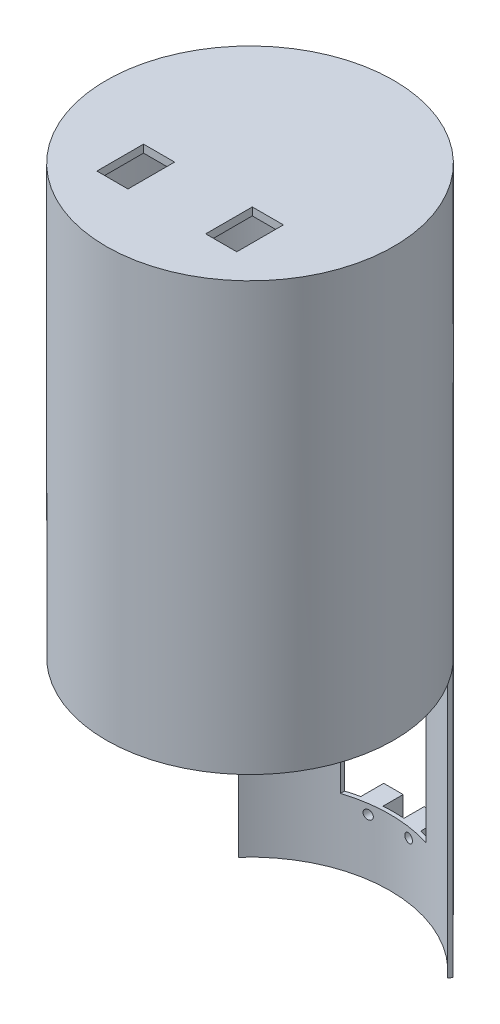
from build123d import *

# Parameters (mm, degrees)
SKETCH_1_R               = 37
EXTRUDE_1_DEPTH          = 110
EXTRUDE_1_DEPTH_BACK     = 70
SKETCH_2_R               = 36
CUT_EXTRUDE_1_DEPTH      = 108
CUT_EXTRUDE_1_DEPTH_BACK = 70
CUT_EXTRUDE_6_DEPTH      = 70
SKETCH_7_W               = 22
SKETCH_7_H               = 20
CUT_EXTRUDE_7_DEPTH      = 43
SKETCH_10_W              = 8
SKETCH_10_H              = 12
CUT_EXTRUDE_8_DEPTH      = 8.1
SKETCH_12_W              = 5
SKETCH_12_H              = 5
SKETCH_12_R              = 1.15
EXTRUDE_3_DEPTH          = 1
EXTRUDE_3_DEPTH_BACK     = 5.1
SKETCH_13_R              = 1.15
CUT_EXTRUDE_9_DEPTH      = 18.4


with BuildPart() as part:
    # 草圖1 → 填料-伸長1 (new body, two sides)
    with BuildSketch(Plane(origin=(0, 0, 0), x_dir=(1, 0, 0), z_dir=(0, 1, 0))) as extrude_1_sk:
        Circle(SKETCH_1_R)
    extrude(amount=EXTRUDE_1_DEPTH)
    extrude(extrude_1_sk.sketch, amount=-EXTRUDE_1_DEPTH_BACK)

    # 草圖2 → 除料-伸長1 (cut, two sides)
    with BuildSketch(Plane(origin=(0, 0, 0), x_dir=(1, 0, 0), z_dir=(0, 1, 0))) as cut_extrude_1_sk:
        Circle(SKETCH_2_R)
    extrude(amount=CUT_EXTRUDE_1_DEPTH, mode=Mode.SUBTRACT)
    extrude(cut_extrude_1_sk.sketch, amount=-CUT_EXTRUDE_1_DEPTH_BACK, mode=Mode.SUBTRACT)

    # 草圖6 → 除料-伸長6 (cut)
    with BuildSketch(Plane(origin=(0, 0, 0), x_dir=(1, 0, 0), z_dir=(0, 1, 0))):
        with BuildLine():
            Line((-36, 0), (26.300758937, 0))
            Line((26.300758937, 0), (36, 0))
            ThreePointArc((36, 0), (33.645512806, 12.805446811), (26.890029553, 23.935879149))
            Line((26.890029553, 23.935879149), (27.509698295, 24.743009108))
            ThreePointArc((27.509698295, 24.743009108), (34.546047798, 13.25030496), (37, 0))
            ThreePointArc((37, 0), (0, -37), (-37, 0))
            ThreePointArc((-37, 0), (-34.546047798, 13.25030496), (-27.509698295, 24.743009108))
            Line((-27.509698295, 24.743009108), (-26.890029553, 23.935879149))
            ThreePointArc((-26.890029553, 23.935879149), (-33.645512806, 12.805446811), (-36, 0))
        make_face()
    extrude(amount=-CUT_EXTRUDE_6_DEPTH, mode=Mode.SUBTRACT)

    # 草圖7 → 除料-伸長7 (cut)
    with BuildSketch(Plane(origin=(0, -10, 0), x_dir=(1, 0, 0), z_dir=(0, 1, 0))):
        with Locations((0, 27.910624132)):
            Rectangle(SKETCH_7_W, SKETCH_7_H)
    extrude(amount=-CUT_EXTRUDE_7_DEPTH, mode=Mode.SUBTRACT)

    # 草圖10 → 除料-伸長8 (cut)
    with BuildSketch(Plane(origin=(0, 110, 0), x_dir=(1, 0, 0), z_dir=(0, 1, 0))):
        with Locations((-13.992241726, -15.397733401)):
            Rectangle(SKETCH_10_W, SKETCH_10_H)
        with Locations((13.992241726, -15.397733401)):
            Rectangle(SKETCH_10_W, SKETCH_10_H)
    extrude(amount=-CUT_EXTRUDE_8_DEPTH, mode=Mode.SUBTRACT)

    # 草圖12 → 填料-伸長3 (add, two sides)
    with BuildSketch(Plane.XY.offset(-37)) as extrude_3_sk:
        with Locations((-5.2, -7.5)):
            Rectangle(SKETCH_12_W, SKETCH_12_H)
        with Locations((-5.2, -7.5)):
            Circle(SKETCH_12_R, mode=Mode.SUBTRACT)
        with Locations((5.2, -7.5)):
            Rectangle(SKETCH_12_W, SKETCH_12_H)
        with Locations((5.2, -7.5)):
            Circle(SKETCH_12_R, mode=Mode.SUBTRACT)
        with Locations((5.2, -55.5)):
            Rectangle(SKETCH_12_W, SKETCH_12_H)
        with Locations((5.2, -55.5)):
            Circle(SKETCH_12_R, mode=Mode.SUBTRACT)
        with Locations((-5.2, -55.5)):
            Rectangle(SKETCH_12_W, SKETCH_12_H)
        with Locations((-5.2, -55.5)):
            Circle(SKETCH_12_R, mode=Mode.SUBTRACT)
    extrude(amount=EXTRUDE_3_DEPTH)
    extrude(extrude_3_sk.sketch, amount=-EXTRUDE_3_DEPTH_BACK)

    # 草圖13 → 除料-伸長9 (cut)
    with BuildSketch(Plane.XY.offset(-37)):
        with Locations((5.2, -7.5)):
            Circle(SKETCH_13_R)
        with Locations((-5.2, -7.5)):
            Circle(SKETCH_13_R)
        with Locations((-5.2, -55.5)):
            Circle(SKETCH_13_R)
        with Locations((5.2, -55.5)):
            Circle(SKETCH_13_R)
    extrude(amount=CUT_EXTRUDE_9_DEPTH, mode=Mode.SUBTRACT)


solid = part.part
